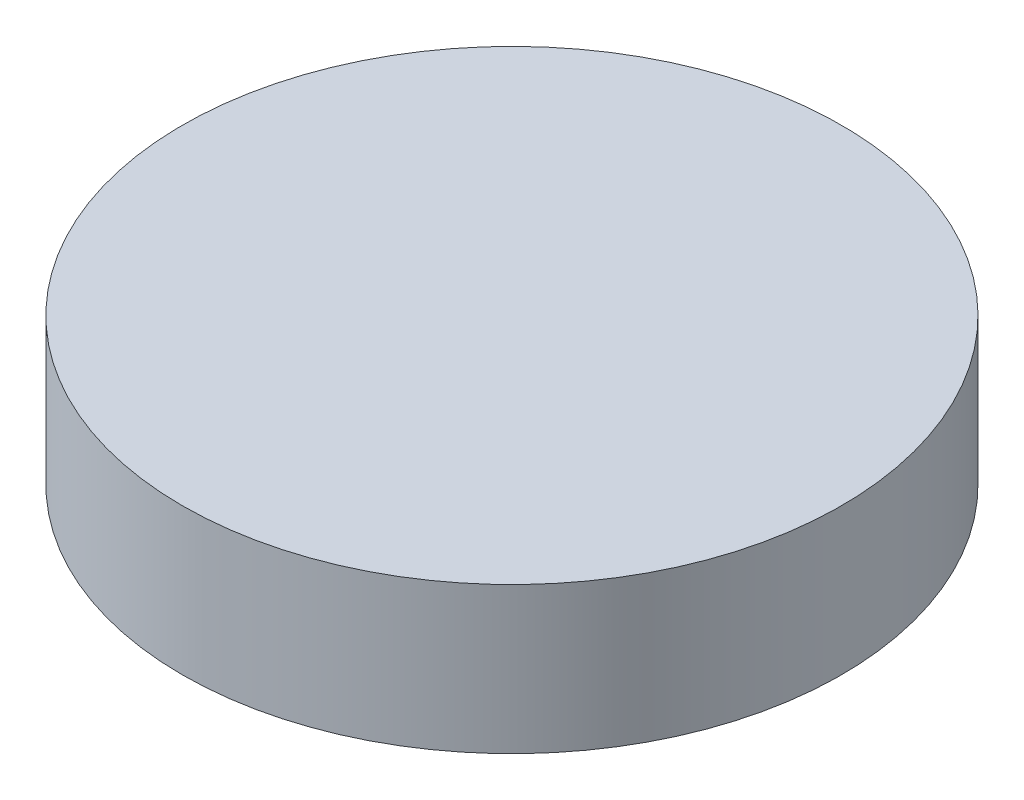
from build123d import *

# Parameters (mm, degrees)
SKETCH1_R           = 114.3
BOSS_EXTRUDE1_DEPTH = 50.8


with BuildPart() as part:
    # Sketch1 → Boss-Extrude1 (new body)
    with BuildSketch(Plane(origin=(0, 0, 0), x_dir=(1, 0, 0), z_dir=(0, 1, 0))):
        Circle(SKETCH1_R)
    extrude(amount=BOSS_EXTRUDE1_DEPTH)


solid = part.part
